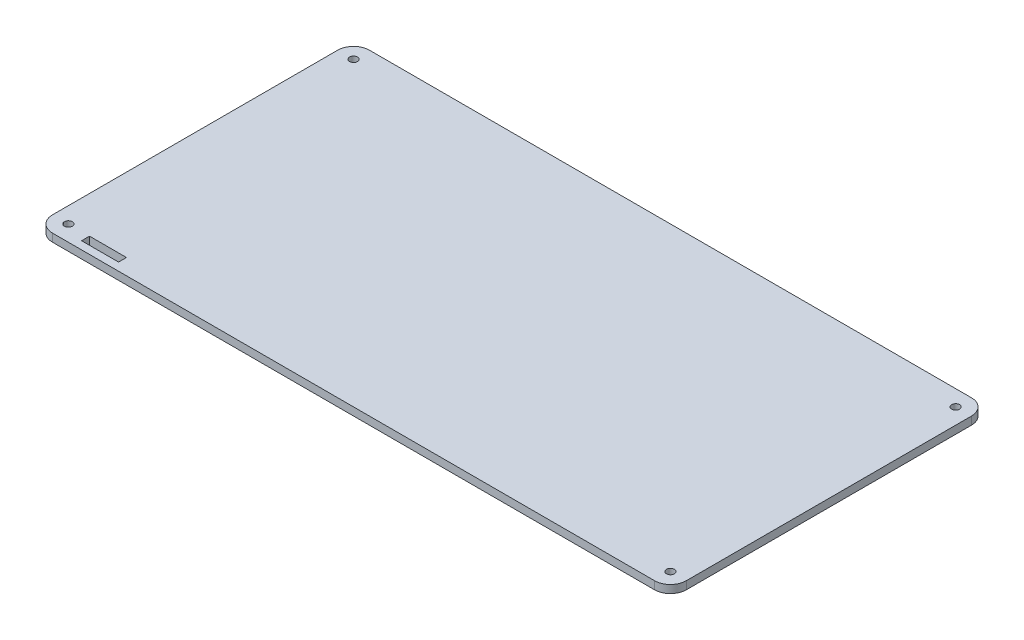
from build123d import *

# Parameters (mm, degrees)
SKETCH1_W           = 240
SKETCH1_H           = 120
SKETCH1_W_2         = 14
SKETCH1_H_2         = 3
BOSS_EXTRUDE1_DEPTH = 3
FILLET1_R           = 6
SKETCH2_R           = 1.5
CUT_EXTRUDE2_DEPTH  = 4


with BuildPart() as part:
    # Sketch1 → Boss-Extrude1 (new body)
    with BuildSketch(Plane(origin=(0, 0, 0), x_dir=(1, 0, 0), z_dir=(0, 1, 0))):
        Rectangle(SKETCH1_W, SKETCH1_H)
        with Locations((-99, -55.5)):
            Rectangle(SKETCH1_W_2, SKETCH1_H_2, mode=Mode.SUBTRACT)
    extrude(amount=BOSS_EXTRUDE1_DEPTH)

    # Fillet1
    fillet1_edges = [part.edges().sort_by_distance(p)[0] for p in [
        (-120, 1.5, -60),
        (120, 1.5, -60),
        (120, 1.5, 60),
        (-120, 1.5, 60),
    ]]
    fillet(fillet1_edges, radius=FILLET1_R)

    # Sketch2 → Cut-Extrude2 (cut, through all)
    with BuildSketch(Plane(origin=(0, 0, 0), x_dir=(1, 0, 0), z_dir=(0, 1, 0))):
        with Locations((-114, 54)):
            Circle(SKETCH2_R)
        with Locations((114, 54)):
            Circle(SKETCH2_R)
        with Locations((-114, -54)):
            Circle(SKETCH2_R)
        with Locations((114, -54)):
            Circle(SKETCH2_R)
    extrude(amount=CUT_EXTRUDE2_DEPTH, mode=Mode.SUBTRACT)


solid = part.part
